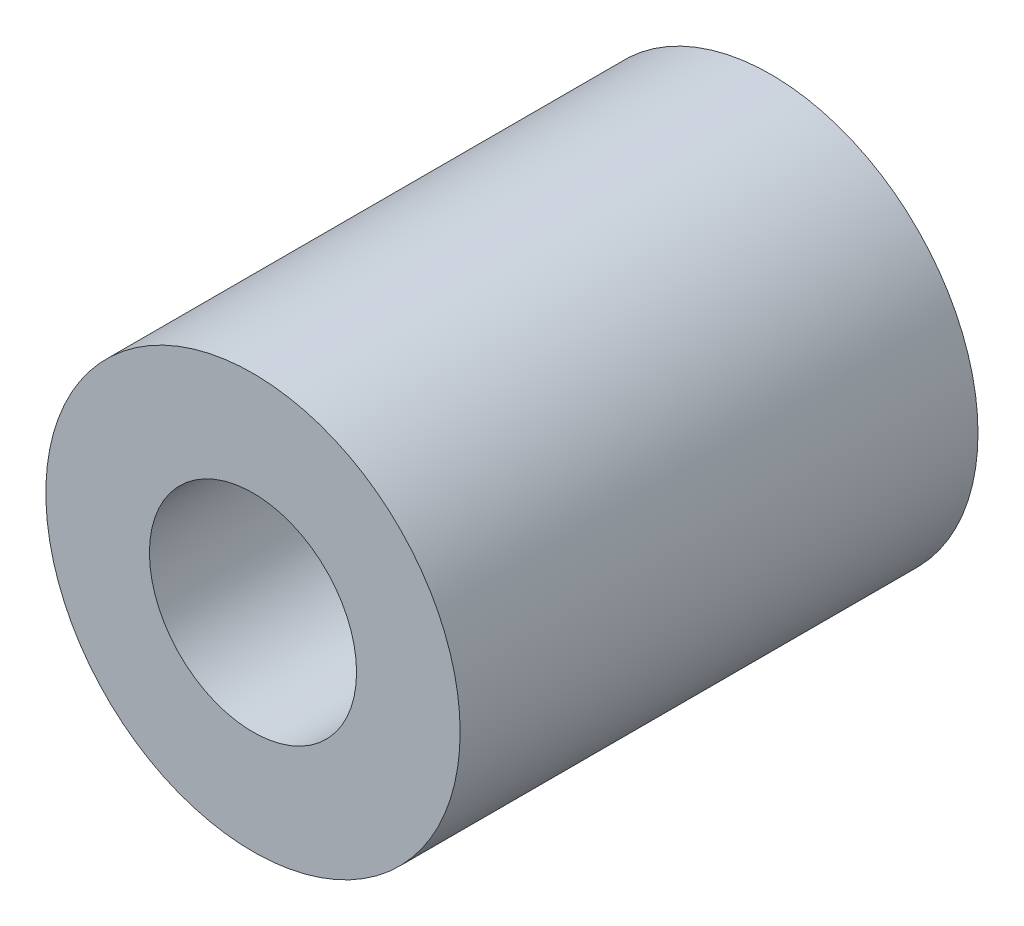
from build123d import *

# Parameters (mm, degrees)
SKETCH2_R           = 6
SKETCH2_R_2         = 3
BOSS_EXTRUDE1_DEPTH = 15


with BuildPart() as part:
    # Sketch2 → Boss-Extrude1 (new body)
    with BuildSketch(Plane.XY):
        Circle(SKETCH2_R)
        Circle(SKETCH2_R_2, mode=Mode.SUBTRACT)
    extrude(amount=BOSS_EXTRUDE1_DEPTH)


solid = part.part
